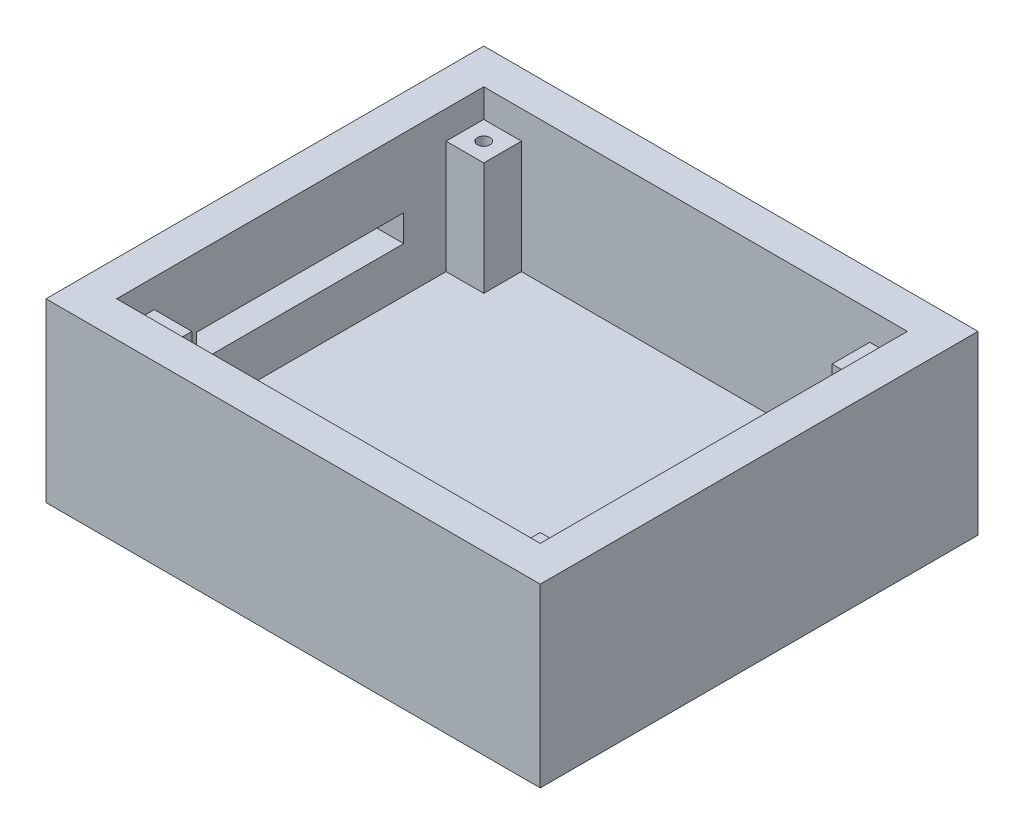
from build123d import *

# Parameters (mm, degrees)
SKETCH1_W           = 114.3
SKETCH1_H           = 99.06
BOSS_EXTRUDE1_DEPTH = 9.525
SKETCH1_3_W         = 133.35
SKETCH1_3_H         = 118.11
SKETCH1_3_W_2       = 114.3
SKETCH1_3_H_2       = 99.06
BOSS_EXTRUDE2_DEPTH = 47.625
SKETCH3_W           = 10.16
SKETCH3_H           = 10.16
SKETCH3_R           = 1.7018
BOSS_EXTRUDE3_DEPTH = 30.48
SKETCH5_W           = 55.88
SKETCH5_H           = 7.239
CUT_EXTRUDE1_DEPTH  = 30.48


with BuildPart() as part:
    # Sketch1 → Boss-Extrude1 (new body)
    with BuildSketch(Plane(origin=(0, 0, 0), x_dir=(1, 0, 0), z_dir=(0, 1, 0))):
        Rectangle(SKETCH1_W, SKETCH1_H)
    extrude(amount=BOSS_EXTRUDE1_DEPTH)

    # Sketch1_3 → Boss-Extrude2 (add)
    with BuildSketch(Plane(origin=(0, 0, 0), x_dir=(1, 0, 0), z_dir=(0, 1, 0))):
        Rectangle(SKETCH1_3_W, SKETCH1_3_H)
        Rectangle(SKETCH1_3_W_2, SKETCH1_3_H_2, mode=Mode.SUBTRACT)
    extrude(amount=BOSS_EXTRUDE2_DEPTH)

    # Sketch3 → Boss-Extrude3 (add)
    # profile 1 of 4: a face of its own
    with BuildSketch(Plane(origin=(0, 9.525, 0), x_dir=(1, 0, 0), z_dir=(0, 1, 0))):
        with Locations((-52.07, 44.45)):
            Rectangle(SKETCH3_W, SKETCH3_H)
        with Locations((-52.07, 44.45)):
            Circle(SKETCH3_R, mode=Mode.SUBTRACT)
    # profile 2 of 4: a face of its own
    with BuildSketch(Plane(origin=(0, 9.525, 0), x_dir=(1, 0, 0), z_dir=(0, 1, 0))):
        with Locations((52.07, 44.45)):
            Rectangle(SKETCH3_W, SKETCH3_H)
        with Locations((52.07, 44.45)):
            Circle(SKETCH3_R, mode=Mode.SUBTRACT)
    # profile 3 of 4: a face of its own
    with BuildSketch(Plane(origin=(0, 9.525, 0), x_dir=(1, 0, 0), z_dir=(0, 1, 0))):
        with Locations((52.07, -44.45)):
            Rectangle(SKETCH3_W, SKETCH3_H)
        with Locations((52.07, -44.45)):
            Circle(SKETCH3_R, mode=Mode.SUBTRACT)
    # profile 4 of 4: a face of its own
    with BuildSketch(Plane(origin=(0, 9.525, 0), x_dir=(1, 0, 0), z_dir=(0, 1, 0))):
        with Locations((-52.07, -44.45)):
            Rectangle(SKETCH3_W, SKETCH3_H)
        with Locations((-52.07, -44.45)):
            Circle(SKETCH3_R, mode=Mode.SUBTRACT)
    extrude(amount=BOSS_EXTRUDE3_DEPTH)

    # Sketch5 → Cut-Extrude1 (cut)
    with BuildSketch(Plane.ZY.offset(66.675)):
        with Locations((0, 25.4)):
            Rectangle(SKETCH5_W, SKETCH5_H)
    extrude(amount=-CUT_EXTRUDE1_DEPTH, mode=Mode.SUBTRACT)


solid = part.part
